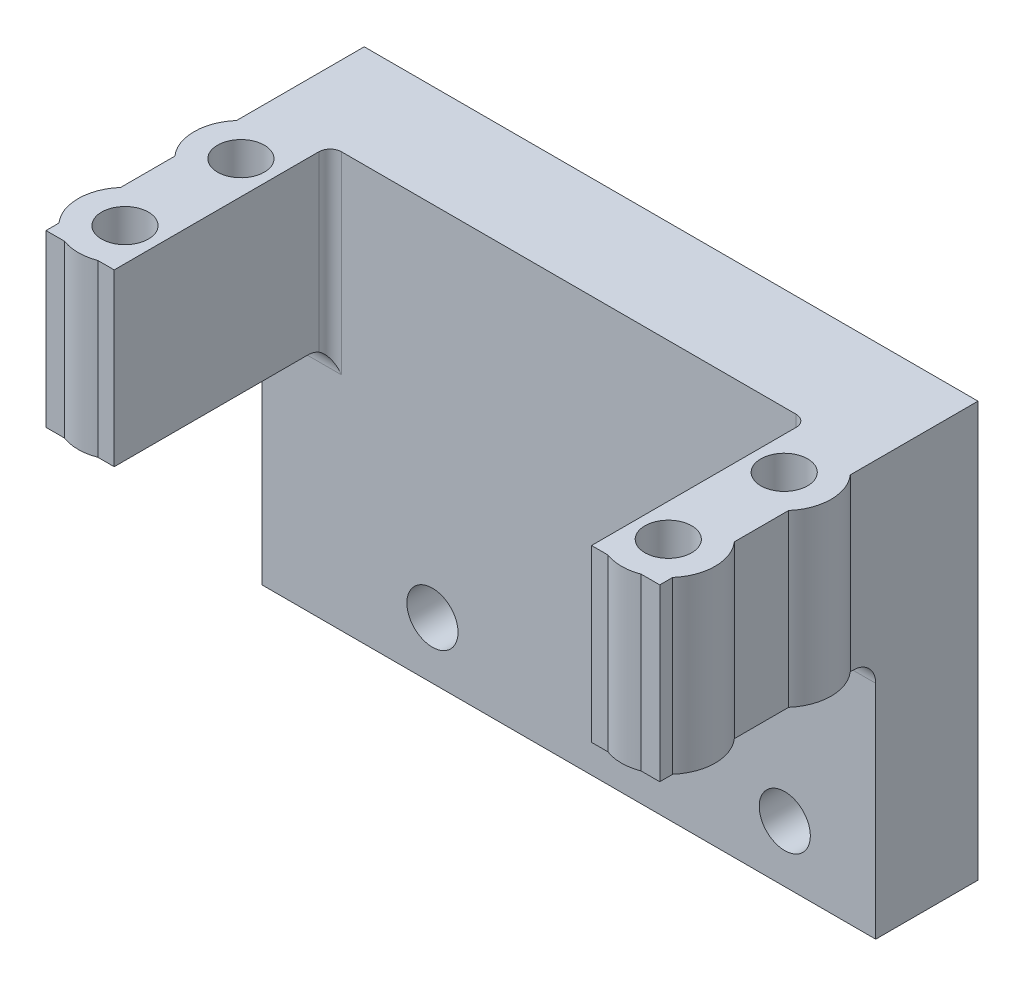
from build123d import *

# Parameters (mm, degrees)
SKETCH1_W           = 54
SKETCH1_H           = 26.5
BOSS_EXTRUDE1_DEPTH = 9
SKETCH2_W           = 6
SKETCH2_H           = 15
BOSS_EXTRUDE2_DEPTH = 19
SKETCH4_R           = 2.06
CUT_EXTRUDE1_DEPTH  = 19
SKETCH5_R           = 2.06
BOSS_EXTRUDE3_DEPTH = 15
SKETCH8_W           = 54
SKETCH8_H           = 10
BOSS_EXTRUDE5_DEPTH = 9
SKETCH9_R           = 2.25
CUT_EXTRUDE3_DEPTH  = 15
FILLET1_R           = 2
FILLET2_R           = 1


with BuildPart() as part:
    # Sketch1 → Boss-Extrude1 (new body)
    with BuildSketch(Plane.XY):
        Rectangle(SKETCH1_W, SKETCH1_H)
    boss_extrude1 = extrude(amount=BOSS_EXTRUDE1_DEPTH)

    # Sketch2 → Boss-Extrude2 (add)
    with BuildSketch(Plane.XY.offset(9)):
        with Locations((24, 5.75)):
            Rectangle(SKETCH2_W, SKETCH2_H)
    boss_extrude2 = extrude(amount=BOSS_EXTRUDE2_DEPTH)

    # Sketch4 → Cut-Extrude1 (cut)
    with BuildSketch(Plane(origin=(0, 13.25, 0), x_dir=(1, 0, 0), z_dir=(0, 1, 0))):
        with Locations((23.9, -13.949454959)):
            Circle(SKETCH4_R)
        with Locations((23.9, -24.149454959)):
            Circle(SKETCH4_R)
    cut_extrude1 = extrude(amount=-CUT_EXTRUDE1_DEPTH, mode=Mode.SUBTRACT)

    # Sketch5 → Boss-Extrude3 (add)
    with BuildSketch(Plane(origin=(0, 13.25, 0), x_dir=(1, 0, 0), z_dir=(0, 1, 0))):
        with BuildLine():
            Line((21, -27.075954574), (21, -21.222955343))
            ThreePointArc((21, -21.222955343), (28.02, -24.149454959), (21, -27.075954574))
        make_face()
        with Locations((23.9, -24.149454959)):
            Circle(SKETCH5_R, mode=Mode.SUBTRACT)
        with BuildLine():
            Line((21, -16.875954574), (21, -11.022955343))
            ThreePointArc((21, -11.022955343), (28.02, -13.949454959), (21, -16.875954574))
        make_face()
        with Locations((23.9, -13.949454959)):
            Circle(SKETCH5_R, mode=Mode.SUBTRACT)
    boss_extrude3 = extrude(amount=-BOSS_EXTRUDE3_DEPTH)

    # Sketch8 → Boss-Extrude5 (add, through all)
    with BuildSketch(Plane.XY.offset(9)):
        with Locations((0, -18.25)):
            Rectangle(SKETCH8_W, SKETCH8_H)
    extrude(amount=-BOSS_EXTRUDE5_DEPTH)

    # Sketch9 → Cut-Extrude3 (cut)
    with BuildSketch(Plane.XY.offset(9)):
        with Locations((19, -18.25)):
            Circle(SKETCH9_R)
        with Locations((-12, -18.25)):
            Circle(SKETCH9_R)
    extrude(amount=-CUT_EXTRUDE3_DEPTH, mode=Mode.SUBTRACT)

    # Mirror1: Boss-Extrude1, Boss-Extrude2, Cut-Extrude1, Boss-Extrude3 across plane
    add(boss_extrude1.mirror(Plane.ZY))
    add(boss_extrude2.mirror(Plane.ZY))
    add(cut_extrude1.mirror(Plane.ZY), mode=Mode.SUBTRACT)
    add(boss_extrude3.mirror(Plane.ZY))

    # Fillet1
    fillet1_edges = [part.edges().sort_by_distance(p)[0] for p in [
        (-24, -1.75, 9),
        (24, -1.75, 9),
    ]]
    fillet(fillet1_edges, radius=FILLET1_R)

    # Fillet2
    fillet2_edges = [part.edges().sort_by_distance(p)[0] for p in [
        (-21, 5.75, 9),
        (21, 5.75, 9),
    ]]
    fillet(fillet2_edges, radius=FILLET2_R)


solid = part.part
